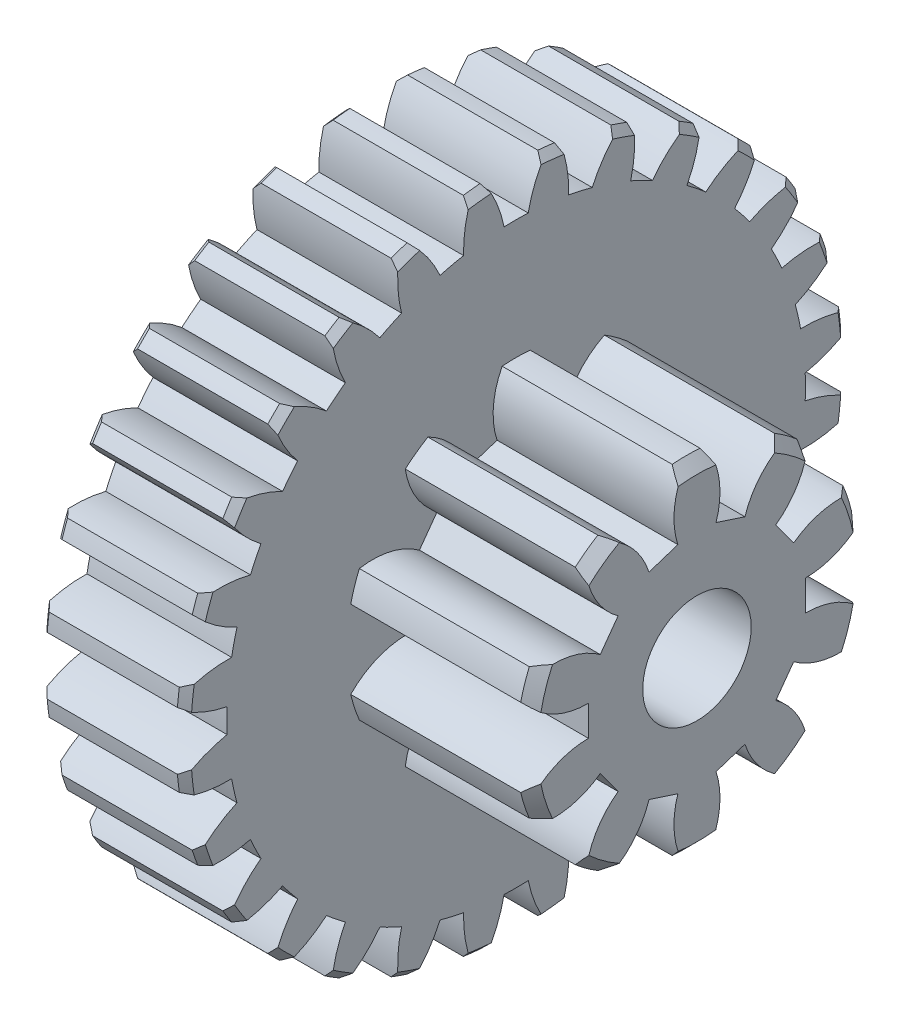
from build123d import *

# Parameters (mm, degrees)
BASPROSKE_W              = 4
BASPROSKE_H              = 9.2
CHAMFER_1_SIZE           = 0.2
TOOTHCUT_DEPTH           = 5
TEETHCUTS_COUNT          = 28
TEETHCUTS_ANGLE          = 347.142857143
SKETCH_1_R               = 4.7
EXTRUDE_1_DEPTH          = 5
CHAMFER_2_SIZE           = 0.3
CUT_EXTRUDE_1_DEPTH      = 5
PATTERN_CIRCULAR_1_COUNT = 10
SKETCH_3_R               = 1.5
CUT_EXTRUDE_2_DEPTH      = 10.0000001
SKETCH_4_R               = 5.5
CUT_EXTRUDE_3_DEPTH      = 2


with BuildPart() as part:
    # BasProSke → Base-Revolve (revolve)
    with BuildSketch(Plane(origin=(0, 0, 0), x_dir=(1, 0, 0), z_dir=(0, 1, 0))):
        with Locations((2, 4.6)):
            Rectangle(BASPROSKE_W, BASPROSKE_H)
    revolve(axis=Axis((-10, 0, 0), (1, 0, 0)))

    # 倒角1
    chamfer_1_edges = [part.edges().sort_by_distance(p)[0] for p in [
        (0, 0, 9.2),
        (4, 0, 9.2),
    ]]
    chamfer(chamfer_1_edges, length=CHAMFER_1_SIZE)

    # TooCutSke → ToothCut (cut, through all)
    with BuildSketch(Plane(origin=(0, 0, 0), x_dir=(0, 0, -1), z_dir=(1, 0, 0))):
        with BuildLine():
            ThreePointArc((0.333945257, 7.993026996), (0, 8), (-0.333945257, 7.993026996))
            ThreePointArc((-0.333945257, 7.993026996), (-0.574844295, 8.745492648), (-0.978380886, 9.424753366))
            ThreePointArc((-0.978380886, 9.424753366), (0, 9.4754), (0.978380886, 9.424753366))
            ThreePointArc((0.978380886, 9.424753366), (0.574844295, 8.745492648), (0.333945257, 7.993026996))
        make_face()
    toothcut = extrude(amount=TOOTHCUT_DEPTH, mode=Mode.SUBTRACT)

    # TeethCuts: ToothCut ×28 about axis
    teethcuts_axis = Axis((-10, 0, 0), (1, 0, 0))
    for i in range(1, TEETHCUTS_COUNT):
        add(toothcut.rotate(teethcuts_axis, i * TEETHCUTS_ANGLE / (TEETHCUTS_COUNT - 1)), mode=Mode.SUBTRACT)

    # 草图1 → 凸台-拉伸1 (add)
    with BuildSketch(Plane(origin=(4, 0, 0), x_dir=(0, 0, -1), z_dir=(1, 0, 0))):
        Circle(SKETCH_1_R)
    extrude(amount=EXTRUDE_1_DEPTH)

    # 倒角2
    chamfer_2_edges = [part.edges().sort_by_distance(p)[0] for p in [
        (9, 0, 4.7),
    ]]
    chamfer(chamfer_2_edges, length=CHAMFER_2_SIZE)

    # 草图2 → 切除-拉伸1 (cut)
    with BuildSketch(Plane(origin=(9, 0, 0), x_dir=(0, 0, -1), z_dir=(1, 0, 0))):
        with BuildLine():
            Line((3, 0.419695711), (3, -0.419695711))
            ThreePointArc((3, -0.419695711), (4.050401619, -0.685177929), (4.846102121, -1.420490842))
            Line((4.846102121, -1.420490842), (4.846102121, 1.420490842))
            ThreePointArc((4.846102121, 1.420490842), (4.050401619, 0.685177929), (3, 0.419695711))
        make_face()
    cut_extrude_1 = extrude(amount=-CUT_EXTRUDE_1_DEPTH, mode=Mode.SUBTRACT)

    # 阵列(圆周)1: 切除-拉伸1 ×10 about axis
    pattern_circular_1_axis = Axis((0, 0, 0), (1, 0, 0))
    for i in range(1, PATTERN_CIRCULAR_1_COUNT):
        add(cut_extrude_1.rotate(pattern_circular_1_axis, i * 360 / PATTERN_CIRCULAR_1_COUNT), mode=Mode.SUBTRACT)

    # 草图3 → 切除-拉伸2 (cut, through all)
    with BuildSketch(Plane(origin=(9, 0, 0), x_dir=(0, 0, -1), z_dir=(1, 0, 0))):
        Circle(SKETCH_3_R)
    extrude(amount=-CUT_EXTRUDE_2_DEPTH, mode=Mode.SUBTRACT)

    # 草图4 → 切除-拉伸3 (cut)
    with BuildSketch(Plane.ZY):
        Circle(SKETCH_4_R)
    extrude(amount=-CUT_EXTRUDE_3_DEPTH, mode=Mode.SUBTRACT)


solid = part.part
